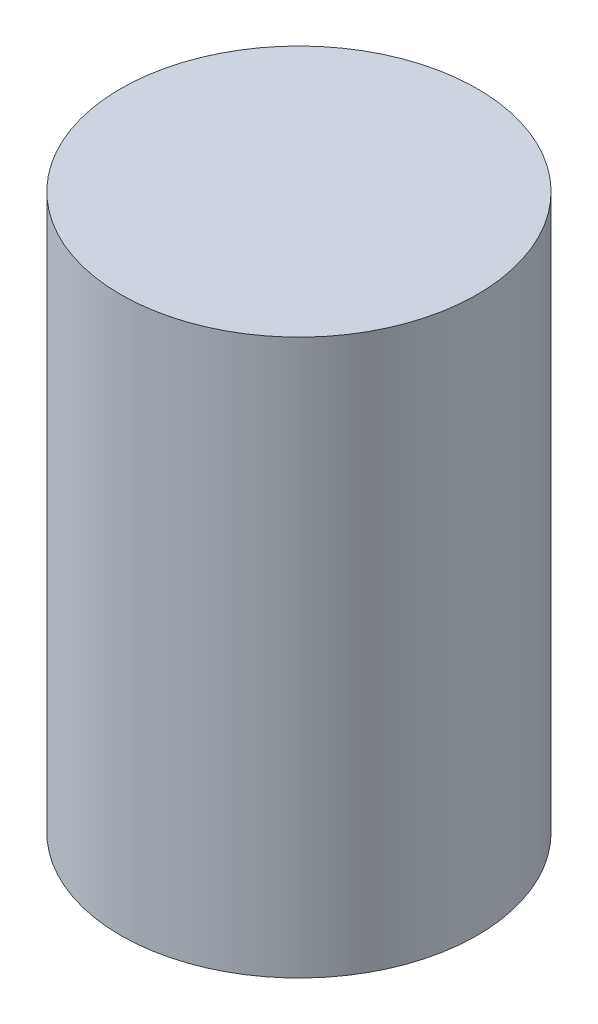
from build123d import *

# Parameters (mm, degrees)
BASE_R              = 6.425
BOSS_EXTRUDE1_DEPTH = 20


with BuildPart() as part:
    # Base → Boss-Extrude1 (new body)
    with BuildSketch(Plane(origin=(0, 0, 0), x_dir=(1, 0, 0), z_dir=(0, 1, 0))):
        Circle(BASE_R)
    extrude(amount=BOSS_EXTRUDE1_DEPTH)


solid = part.part
